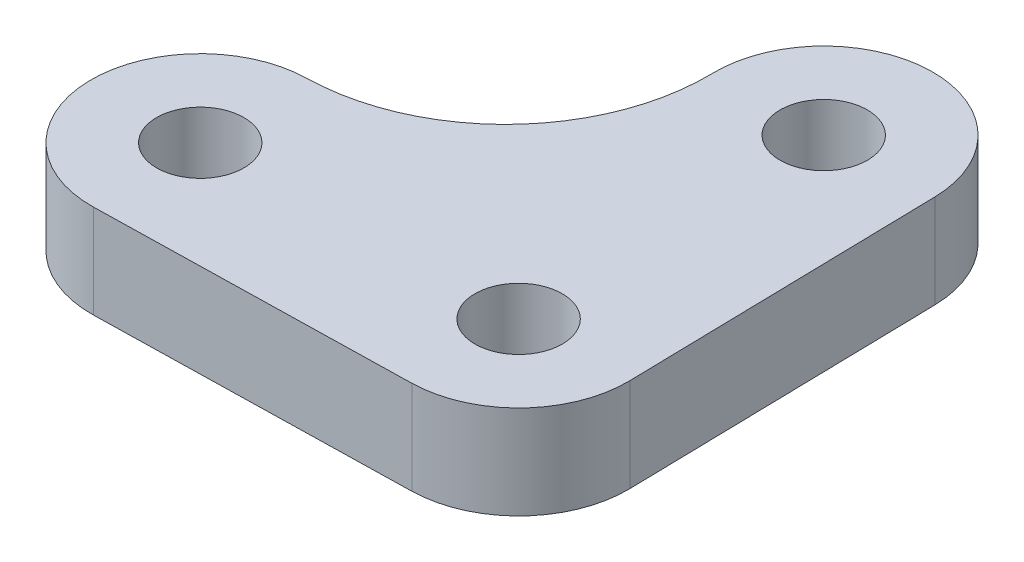
from build123d import *

# Parameters (mm, degrees)
SKETCH1_R           = 1.4
BOSS_EXTRUDE1_DEPTH = 3


with BuildPart() as part:
    # Sketch1 → Boss-Extrude1 (new body)
    with BuildSketch(Plane(origin=(0, 0, 0), x_dir=(1, 0, 0), z_dir=(0, 1, 0))):
        with BuildLine():
            Line((8.498085152, -4.818460921), (8.285834919, 5.179286318))
            ThreePointArc((8.285834919, 5.179286318), (4.712335804, 8.604210269), (1.287411852, 5.030711154))
            ThreePointArc((1.287411852, 5.030711154), (-0.518410861, 0.395144164), (-5.073161201, -1.605787202))
            ThreePointArc((-5.073161201, -1.605787202), (-8.498085152, -5.179286318), (-4.924586037, -8.604210269))
            Line((-4.924586037, -8.604210269), (5.073161201, -8.391960036))
            ThreePointArc((5.073161201, -8.391960036), (7.525719076, -7.314535454), (8.498085152, -4.818460921))
        make_face()
        with Locations((4.786623386, 5.104998736)):
            Circle(SKETCH1_R, mode=Mode.SUBTRACT)
        with Locations((4.998873619, -4.892748502)):
            Circle(SKETCH1_R, mode=Mode.SUBTRACT)
        with Locations((-4.998873619, -5.104998736)):
            Circle(SKETCH1_R, mode=Mode.SUBTRACT)
    extrude(amount=BOSS_EXTRUDE1_DEPTH)


solid = part.part
